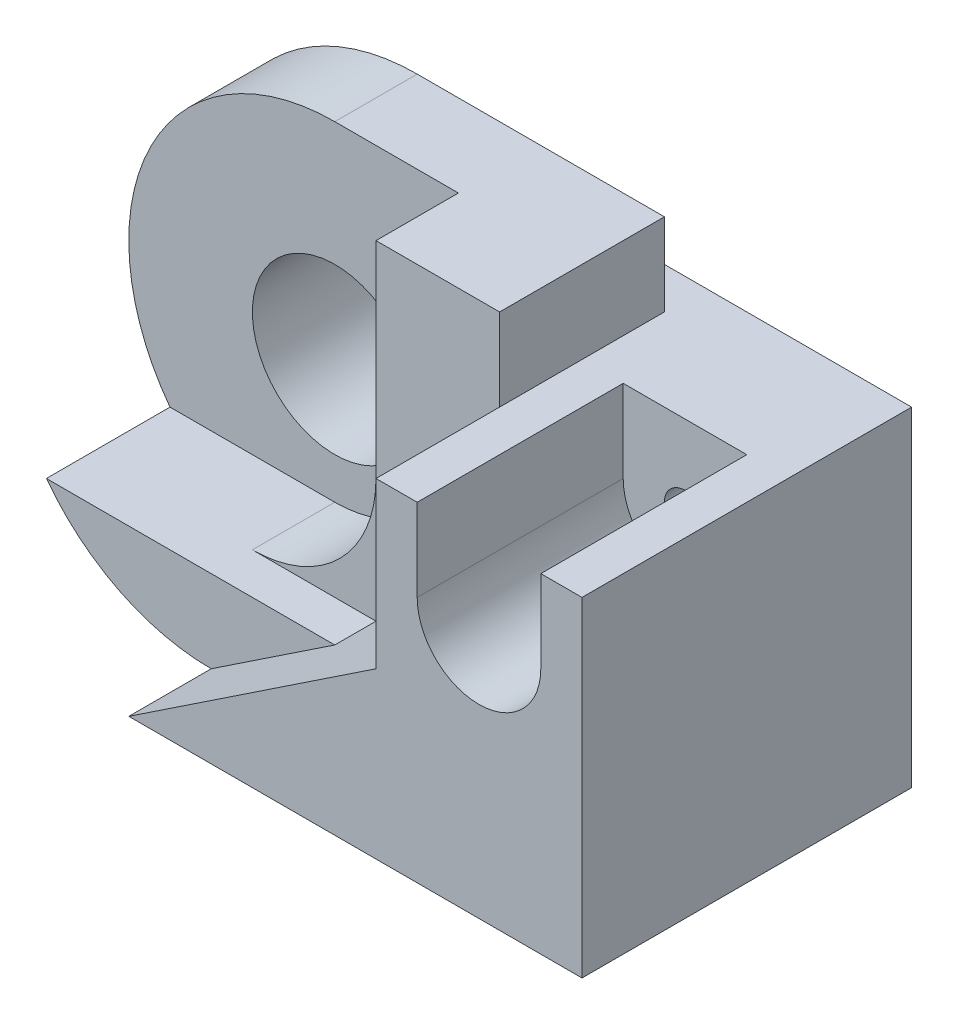
from build123d import *

# Parameters (mm, degrees)
SKETCH1_R                 = 2
BOSS_EXTRUDE1_DEPTH       = 3
SKETCH2_W                 = 1
SKETCH2_H                 = 2
CUT_EXTRUDE1_DEPTH        = 15
SKETCH3_R                 = 0.5
BOSS_EXTRUDE2_DEPTH       = 5
CUT_EXTRUDE2_DEPTH        = 5
BOSS_EXTRUDE3_DEPTH       = 3
BOSS_EXTRUDE4_DEPTH       = 2
F_1_0MM_DOWEL_HOLE1_D     = 1
F_1_0MM_DOWEL_HOLE1_DEPTH = 2
F_1_0MM_DOWEL_HOLE1_TIP   = 0.30043031


with BuildPart() as part:
    # Sketch1 → Boss-Extrude1 (new body)
    with BuildSketch(Plane.XY):
        with BuildLine():
            Line((0, 0), (11, 0))
            Line((11, 0), (11, 8))
            Line((11, 8), (6, 8))
            Line((6, 8), (6, 10))
            Line((6, 10), (0, 10))
            ThreePointArc((0, 10), (-5, 5), (0, 0))
        make_face()
        with Locations((0, 5)):
            Circle(SKETCH1_R, mode=Mode.SUBTRACT)
    extrude(amount=BOSS_EXTRUDE1_DEPTH)

    # Sketch2 → Cut-Extrude1 (cut)
    with BuildSketch(Plane(origin=(6, 0, 0), x_dir=(0, 0, -1), z_dir=(1, 0, 0))):
        with Locations((-0.5, 9)):
            Rectangle(SKETCH2_W, SKETCH2_H)
    extrude(amount=-CUT_EXTRUDE1_DEPTH, mode=Mode.SUBTRACT)

    # Sketch3 → Boss-Extrude2 (add)
    with BuildSketch(Plane.XY.offset(3)):
        Polygon((11, 8), (11, 0), (0, 0), (6, 4), (6, 8), align=None)
        with Locations((8.5, 6)):
            Circle(SKETCH3_R, mode=Mode.SUBTRACT)
    extrude(amount=BOSS_EXTRUDE2_DEPTH)

    # Sketch4 → Cut-Extrude2 (cut)
    with BuildSketch(Plane.XY.offset(8)):
        with BuildLine():
            Line((7, 8), (7, 6))
            ThreePointArc((7, 6), (8.5, 4.5), (10, 6))
            Line((10, 6), (10, 8))
            Line((10, 8), (7, 8))
        make_face()
    extrude(amount=-CUT_EXTRUDE2_DEPTH, mode=Mode.SUBTRACT)

    # Sketch5 → Boss-Extrude3 (add)
    with BuildSketch(Plane.XY.offset(3)):
        with BuildLine():
            Line((3, 2), (-4, 2))
            ThreePointArc((-4, 2), (-2.236067977, 0.527864045), (0, 0))
            Line((0, 0), (3, 2))
        make_face()
    extrude(amount=BOSS_EXTRUDE3_DEPTH)

    # Sketch6 → Boss-Extrude4 (add)
    with BuildSketch(Plane.XY.offset(3)):
        with BuildLine():
            Line((3, 10), (3, 5))
            ThreePointArc((3, 5), (2.121320344, 2.878679656), (0, 2))
            Line((0, 2), (3, 2))
            Line((3, 2), (6, 4))
            Line((6, 4), (6, 10))
            Line((6, 10), (3, 10))
        make_face()
    extrude(amount=BOSS_EXTRUDE4_DEPTH)

    # Ø1.0mm Dowel Hole1
    with Locations(Plane(origin=(8.5, 6, 3), x_dir=(1, 0, 0), z_dir=(0, 0, 1))):
        with Locations((0, 0)):
            Hole(F_1_0MM_DOWEL_HOLE1_D / 2, depth=F_1_0MM_DOWEL_HOLE1_DEPTH)
            with Locations((0, 0, -(F_1_0MM_DOWEL_HOLE1_DEPTH + F_1_0MM_DOWEL_HOLE1_TIP / 2))):  # 118° drill point
                Cone(0, F_1_0MM_DOWEL_HOLE1_D / 2, F_1_0MM_DOWEL_HOLE1_TIP, mode=Mode.SUBTRACT)


solid = part.part
